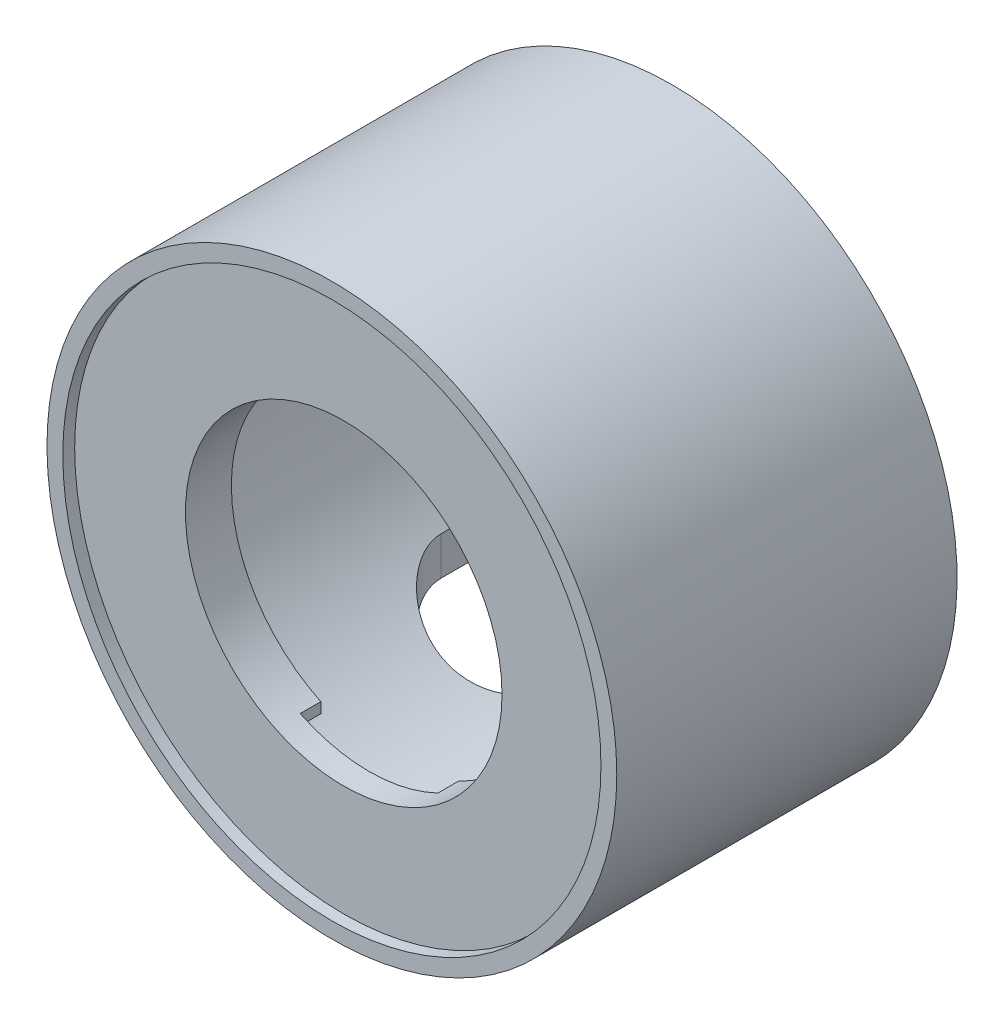
from build123d import *

# Parameters (mm, degrees)
SKETCH_1_R               = 36
EXTRUDE_1_DEPTH          = 43
SKETCH_2_R               = 34
CUT_EXTRUDE_1_DEPTH      = 1.5
SKETCH_5_R               = 32.5
CUT_EXTRUDE_2_DEPTH      = 38.3
SKETCH_6_R               = 21.2
EXTRUDE_2_DEPTH          = 2.6
CUT_EXTRUDE_3_DEPTH      = 7
CUT_EXTRUDE_3_DEPTH_BACK = 8.6
SKETCH_6_3_R             = 20
CUT_EXTRUDE_4_DEPTH      = 67.640828326
CUT_EXTRUDE_5_DEPTH      = 3


with BuildPart() as part:
    # 草图1 → 凸台-拉伸1 (new body)
    with BuildSketch(Plane.XY):
        Circle(SKETCH_1_R)
    extrude(amount=EXTRUDE_1_DEPTH)

    # 草图2 → 切除-拉伸1 (cut)
    with BuildSketch(Plane.XY.offset(43)):
        Circle(SKETCH_2_R)
    extrude(amount=-CUT_EXTRUDE_1_DEPTH, mode=Mode.SUBTRACT)

    # 草图5 → 切除-拉伸2 (cut)
    with BuildSketch(Plane(origin=(0, 0, 0), x_dir=(-1, 0, 0), z_dir=(0, 0, -1))):
        Circle(SKETCH_5_R)
    extrude(amount=-CUT_EXTRUDE_2_DEPTH, mode=Mode.SUBTRACT)

    # 草图6 → 凸台-拉伸2 (add)
    with BuildSketch(Plane(origin=(0, 0, 38.3), x_dir=(-1, 0, 0), z_dir=(0, 0, -1))):
        Circle(SKETCH_6_R)
    extrude(amount=EXTRUDE_2_DEPTH)

    # 草图6<3> → 切除-拉伸3 (cut, two sides: drawn at the far end of the back side and taken through both)
    with BuildSketch(Plane(origin=(0, 0, 38.3), x_dir=(-1, 0, 0), z_dir=(0, 0, -1)).offset(-CUT_EXTRUDE_3_DEPTH_BACK)):
        Circle(SKETCH_6_3_R)
    extrude(amount=CUT_EXTRUDE_3_DEPTH + CUT_EXTRUDE_3_DEPTH_BACK, mode=Mode.SUBTRACT)

    # 草图3 → 切除-拉伸4 (cut, through all)
    with BuildSketch(Plane(origin=(0, 0, 0), x_dir=(1, 0, 0), z_dir=(0, 1, 0))):
        with BuildLine():
            Line((-23.7, 0), (-23.7, -5.5))
            ThreePointArc((-23.7, -5.5), (-16.2, -13), (-8.7, -5.5))
            Line((-8.7, -5.5), (-8.7, 0))
            Line((-8.7, 0), (-23.7, 0))
        make_face()
        with BuildLine():
            Line((8.7, 0), (8.7, -5.5))
            ThreePointArc((8.7, -5.5), (16.2, -13), (23.7, -5.5))
            Line((23.7, -5.5), (23.7, 0))
            Line((23.7, 0), (8.7, 0))
        make_face()
    extrude(amount=-CUT_EXTRUDE_4_DEPTH, mode=Mode.SUBTRACT)

    # 草图7 → 切除-拉伸5 (cut)
    with BuildSketch(Plane(origin=(0, 0, 38.3), x_dir=(-1, 0, 0), z_dir=(0, 0, -1))):
        with BuildLine():
            Line((-8.7, -18.008609052), (-8.7, -19.332614929))
            ThreePointArc((-8.7, -19.332614929), (0, -21.2), (8.7, -19.332614929))
            Line((8.7, -19.332614929), (8.7, -18.008609052))
            ThreePointArc((8.7, -18.008609052), (0, -20), (-8.7, -18.008609052))
        make_face()
    extrude(amount=CUT_EXTRUDE_5_DEPTH, mode=Mode.SUBTRACT)


solid = part.part
